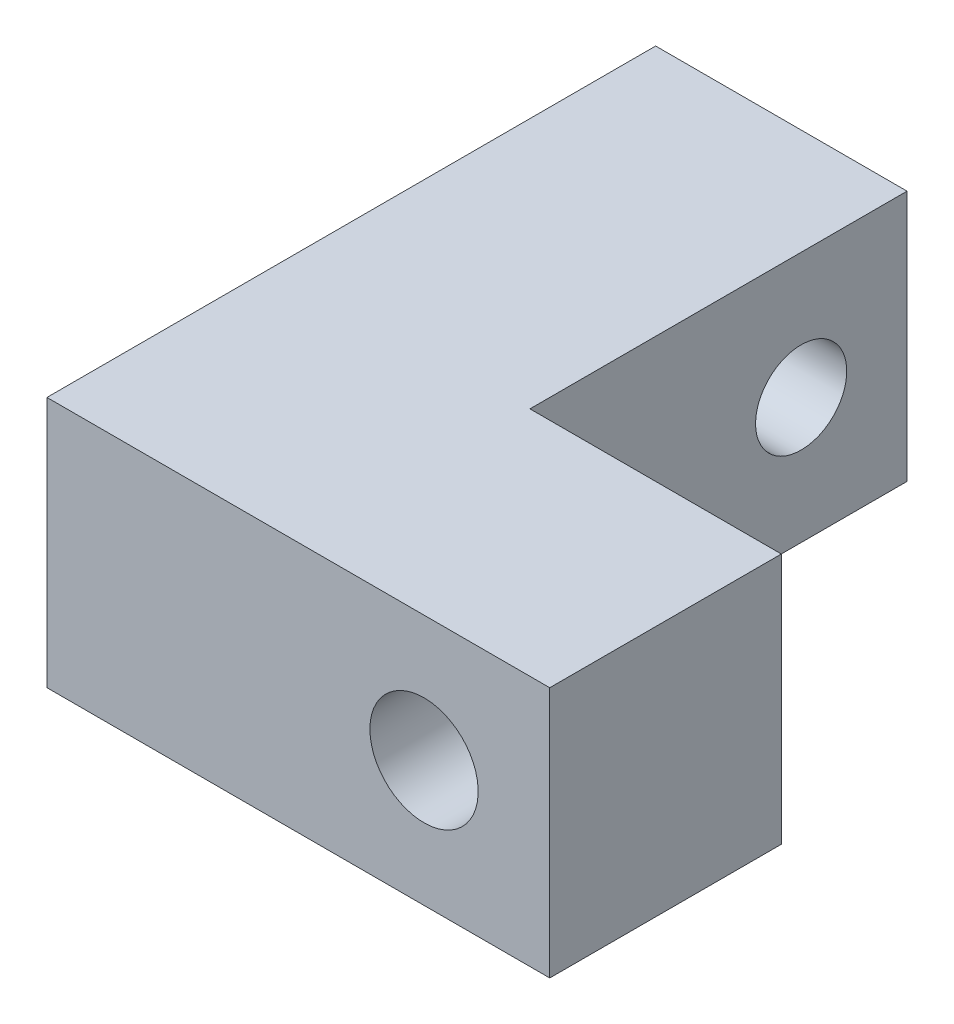
from build123d import *

# Parameters (mm, degrees)
SKETCH1_W                          = 38.1
SKETCH1_H                          = 47.625
BOSS_EXTRUDE1_DEPTH                = 19.05
CUT_EXTRUDE1_REACH                 = 21.05
SKETCH2_W                          = 19.05
SKETCH2_H                          = 28.575
F_5_16_24_TAPPED_HOLE1_D           = 6.9088
F_5_16_24_TAPPED_HOLE1_DEPTH       = 19.06
F_5_16_24_TAPPED_HOLE1_CSINK_D     = 9.2075
F_5_16_24_TAPPED_HOLE1_CSINK_ANGLE = 90
F_5_16_24_TAPPED_HOLE1_TIP         = 2.075612922
F_5_16_CLEARANCE_HOLE1_D           = 8.2042
F_5_16_CLEARANCE_HOLE1_CSINK_D     = 9.4742
F_5_16_CLEARANCE_HOLE1_CSINK_ANGLE = 90
CHAMFER1_SIZE                      = 1.5


with BuildPart() as part:
    # Sketch1 → Boss-Extrude1 (new body)
    with BuildSketch(Plane(origin=(0, 0, 0), x_dir=(1, 0, 0), z_dir=(0, 1, 0))):
        Rectangle(SKETCH1_W, SKETCH1_H)
    extrude(amount=BOSS_EXTRUDE1_DEPTH)

    # Sketch2 → Cut-Extrude1 (cut, up to next)
    with BuildSketch(Plane(origin=(0, 19.05, 0), x_dir=(1, 0, 0), z_dir=(0, 1, 0)), mode=Mode.PRIVATE) as cut_extrude1_sk1:
        with Locations((9.525, 9.525)):
            Rectangle(SKETCH2_W, SKETCH2_H)
    cut_extrude1_tool1 = extrude(cut_extrude1_sk1.sketch, amount=-CUT_EXTRUDE1_REACH, mode=Mode.PRIVATE) & part.part
    add(cut_extrude1_tool1.solids().sort_by_distance((9.525, 19.05, -9.525))[0], mode=Mode.SUBTRACT)

    # 5/16-24 Tapped Hole1
    with Locations(Plane.ZY.offset(19.05)):
        with Locations((-14.2875, 9.525), (11.1125, 9.525)):
            CounterSinkHole(F_5_16_24_TAPPED_HOLE1_D / 2, F_5_16_24_TAPPED_HOLE1_CSINK_D / 2, depth=F_5_16_24_TAPPED_HOLE1_DEPTH, counter_sink_angle=F_5_16_24_TAPPED_HOLE1_CSINK_ANGLE)
            with Locations((0, 0, -(F_5_16_24_TAPPED_HOLE1_DEPTH + F_5_16_24_TAPPED_HOLE1_TIP / 2))):  # 118° drill point
                Cone(0, F_5_16_24_TAPPED_HOLE1_D / 2, F_5_16_24_TAPPED_HOLE1_TIP, mode=Mode.SUBTRACT)

    # 5/16 Clearance Hole1 (through all)
    with Locations(Plane(origin=(0, 0, 4.7625), x_dir=(-1, 0, 0), z_dir=(0, 0, -1))):
        with Locations((-9.525, 9.525)):
            CounterSinkHole(F_5_16_CLEARANCE_HOLE1_D / 2, F_5_16_CLEARANCE_HOLE1_CSINK_D / 2, counter_sink_angle=F_5_16_CLEARANCE_HOLE1_CSINK_ANGLE)

    # Chamfer1
    chamfer1_edges = [part.edges().sort_by_distance(p)[0] for p in [
        (-9.525, 0, -23.8125),
        (-9.525, 19.05, -23.8125),
        (9.525, 0, 4.7625),
        (19.05, 9.525, 4.7625),
        (0, 9.525, -23.8125),
        (9.525, 19.05, 4.7625),
    ]]
    chamfer(chamfer1_edges, length=CHAMFER1_SIZE)


solid = part.part
